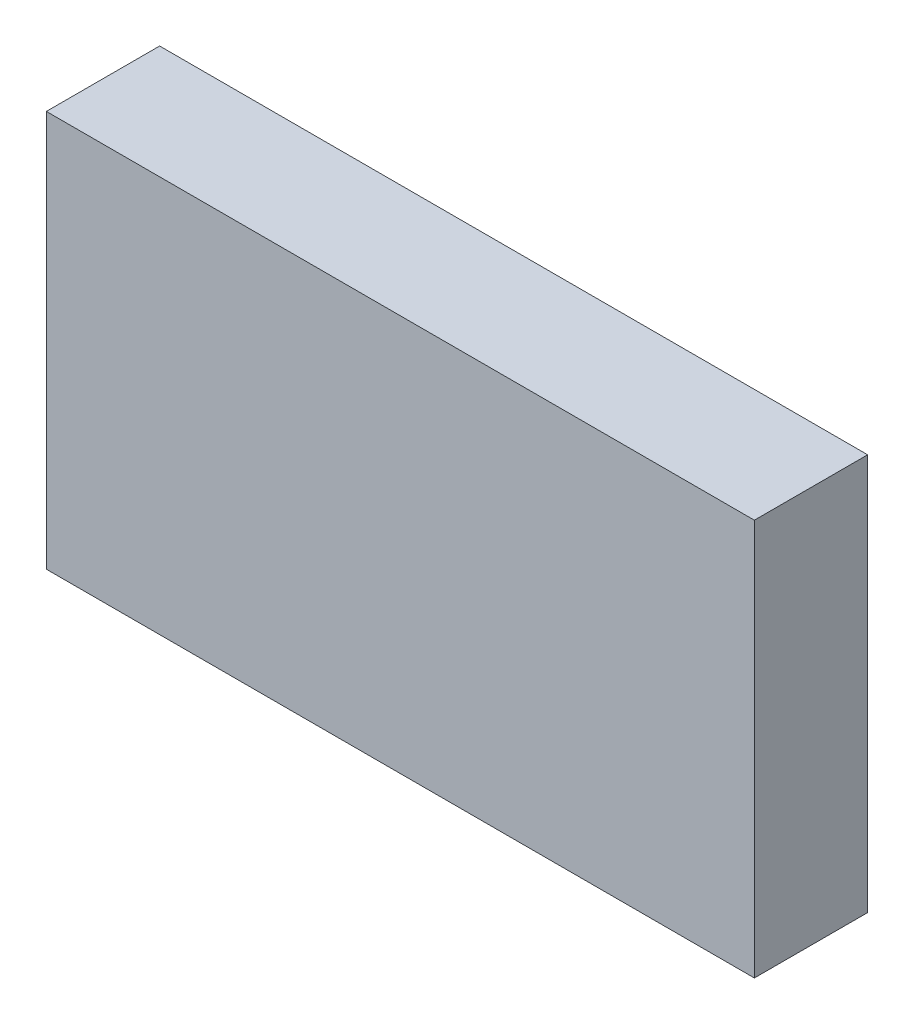
from build123d import *

# Parameters (mm, degrees)
SKETCH1_W      = 152.4
SKETCH1_H      = 82.55
EXTRUDE1_DEPTH = 19.05
SKETCH2_W      = 131.445
SKETCH2_H      = 72.39
EXTRUDE2_DEPTH = 12.7
FILLET1_R      = 2.54
FILLET2_R      = 5.08
SKETCH3_W      = 10.795
SKETCH3_H      = 44.45
EXTRUDE3_DEPTH = 6.35
FILLET3_R      = 5.08
SKETCH4_W      = 158.75
SKETCH4_H      = 88.9
STOCK_DEPTH    = 25.4


with BuildPart() as part:
    # Sketch1 → Extrude1 (new body)
    with BuildSketch(Plane.XY):
        Rectangle(SKETCH1_W, SKETCH1_H)
    extrude(amount=EXTRUDE1_DEPTH)

    # Sketch2 → Extrude2 (cut)
    with BuildSketch(Plane.XY.offset(19.05)):
        with Locations((5.3975, 0)):
            Rectangle(SKETCH2_W, SKETCH2_H)
    extrude(amount=-EXTRUDE2_DEPTH, mode=Mode.SUBTRACT)

    # Fillet1
    fillet1_edges = [part.edges().sort_by_distance(p)[0] for p in [
        (76.2, -41.275, 9.525),
        (-76.2, -41.275, 9.525),
        (-76.2, 41.275, 9.525),
        (76.2, 41.275, 9.525),
    ]]
    fillet(fillet1_edges, radius=FILLET1_R)

    # Fillet2
    fillet2_edges = [part.edges().sort_by_distance(p)[0] for p in [
        (71.12, 36.195, 12.7),
        (71.12, -36.195, 12.7),
        (-60.325, -36.195, 12.7),
        (-60.325, 36.195, 12.7),
    ]]
    fillet(fillet2_edges, radius=FILLET2_R)

    # Sketch3 → Extrude3 (cut)
    with BuildSketch(Plane.XY.offset(19.05)):
        with Locations((-65.7225, 0)):
            Rectangle(SKETCH3_W, SKETCH3_H)
    extrude(amount=-EXTRUDE3_DEPTH, mode=Mode.SUBTRACT)

    # Fillet3
    fillet3_edges = [part.edges().sort_by_distance(p)[0] for p in [
        (-71.12, -22.225, 15.875),
        (-71.12, 22.225, 15.875),
    ]]
    fillet(fillet3_edges, radius=FILLET3_R)


with BuildPart() as body_2:
    # Sketch4 → Stock (new body)
    with BuildSketch(Plane.XY.offset(19.05)):
        Rectangle(SKETCH4_W, SKETCH4_H)
    extrude(amount=-STOCK_DEPTH)


solid = Compound([part.part, body_2.part])
